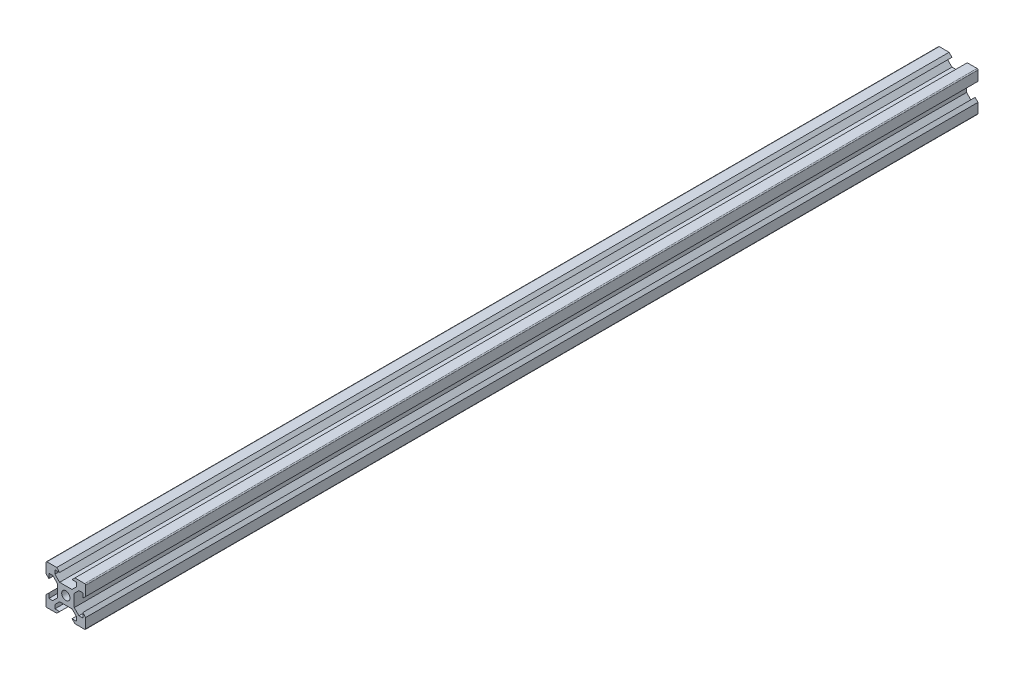
from build123d import *

# Parameters (mm, degrees)
SKETCH1_R           = 2.1
BOSS_EXTRUDE1_DEPTH = 450


with BuildPart() as part:
    # Sketch1 → Boss-Extrude1 (new body)
    with BuildSketch(Plane.XY):
        with BuildLine():
            Line((-3.125, 4.245), (3.125, 4.245))
            Line((3.125, 4.245), (5.5, 6.62))
            Line((5.5, 6.62), (5.5, 8.545))
            Line((5.5, 8.545), (3.125, 8.545))
            Line((3.125, 8.545), (4.58, 10))
            Line((4.58, 10), (9.5, 10))
            ThreePointArc((9.5, 10), (9.853553391, 9.853553391), (10, 9.5))
            Line((10, 9.5), (10, 4.58))
            Line((10, 4.58), (8.545, 3.125))
            Line((8.545, 3.125), (8.545, 5.5))
            Line((8.545, 5.5), (6.62, 5.5))
            Line((6.62, 5.5), (4.245, 3.125))
            Line((4.245, 3.125), (4.245, -3.125))
            Line((4.245, -3.125), (6.62, -5.5))
            Line((6.62, -5.5), (8.545, -5.5))
            Line((8.545, -5.5), (8.545, -3.125))
            Line((8.545, -3.125), (10, -4.58))
            Line((10, -4.58), (10, -9.5))
            ThreePointArc((10, -9.5), (9.853553391, -9.853553391), (9.5, -10))
            Line((9.5, -10), (4.58, -10))
            Line((4.58, -10), (3.125, -8.545))
            Line((3.125, -8.545), (5.5, -8.545))
            Line((5.5, -8.545), (5.5, -6.62))
            Line((5.5, -6.62), (3.125, -4.245))
            Line((3.125, -4.245), (-3.125, -4.245))
            Line((-3.125, -4.245), (-5.5, -6.62))
            Line((-5.5, -6.62), (-5.5, -8.545))
            Line((-5.5, -8.545), (-3.125, -8.545))
            Line((-3.125, -8.545), (-4.58, -10))
            Line((-4.58, -10), (-9.5, -10))
            ThreePointArc((-9.5, -10), (-9.853553391, -9.853553391), (-10, -9.5))
            Line((-10, -9.5), (-10, -4.58))
            Line((-10, -4.58), (-8.545, -3.125))
            Line((-8.545, -3.125), (-8.545, -5.5))
            Line((-8.545, -5.5), (-6.62, -5.5))
            Line((-6.62, -5.5), (-4.245, -3.125))
            Line((-4.245, -3.125), (-4.245, 3.125))
            Line((-4.245, 3.125), (-6.62, 5.5))
            Line((-6.62, 5.5), (-8.545, 5.5))
            Line((-8.545, 5.5), (-8.545, 3.125))
            Line((-8.545, 3.125), (-10, 4.58))
            Line((-10, 4.58), (-10, 9.5))
            ThreePointArc((-10, 9.5), (-9.853553391, 9.853553391), (-9.5, 10))
            Line((-9.5, 10), (-4.58, 10))
            Line((-4.58, 10), (-3.125, 8.545))
            Line((-3.125, 8.545), (-5.5, 8.545))
            Line((-5.5, 8.545), (-5.5, 6.62))
            Line((-5.5, 6.62), (-3.125, 4.245))
        make_face()
        Circle(SKETCH1_R, mode=Mode.SUBTRACT)
    extrude(amount=BOSS_EXTRUDE1_DEPTH)


solid = part.part
